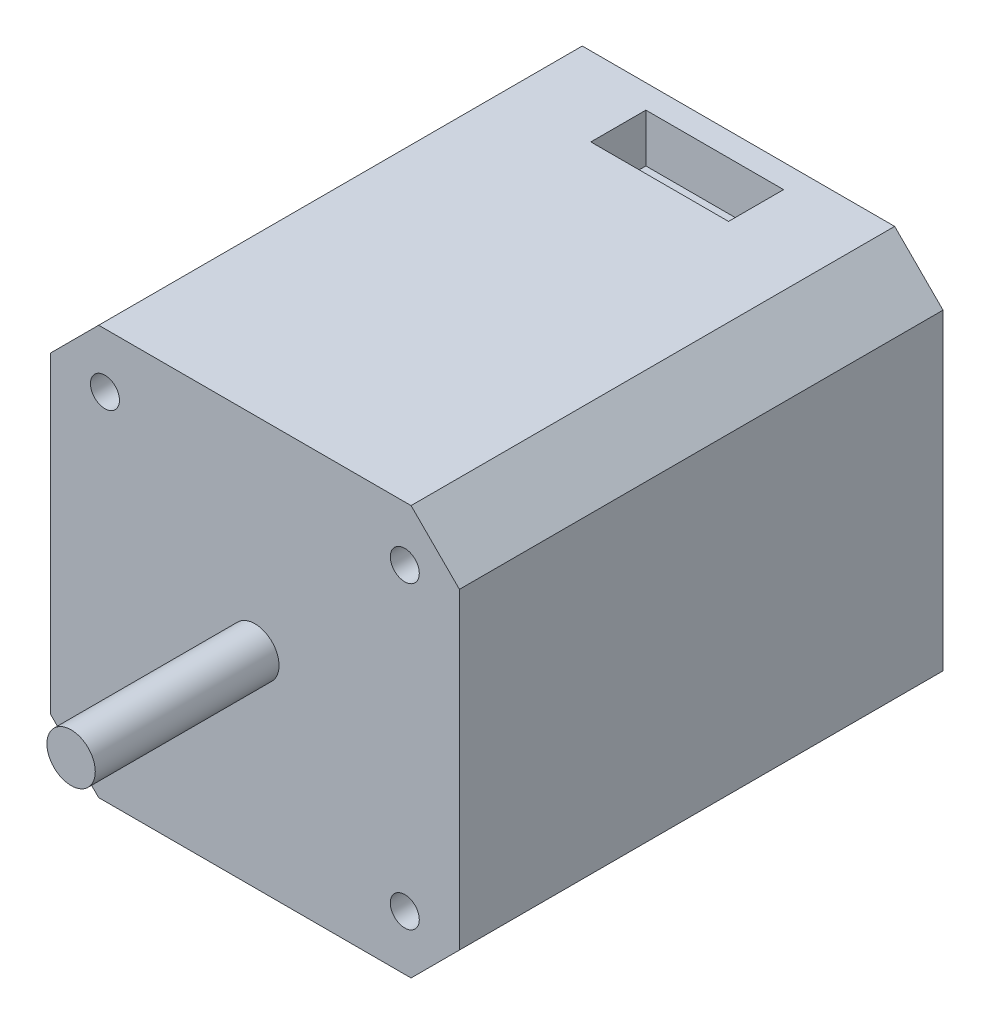
from build123d import *

# Parameters (mm, degrees)
BOSS_EXTRUDE1_DEPTH = 50
SKETCH2_R           = 2.5
BOSS_EXTRUDE2_DEPTH = 24
SKETCH3_R           = 1.5
CUT_EXTRUDE1_DEPTH  = 24
SKETCH4_W           = 14.23576085
SKETCH4_H           = 5.694304341
CUT_EXTRUDE2_DEPTH  = 5
SKETCH6_R           = 2.5
CUT_EXTRUDE3_DEPTH  = 5


with BuildPart() as part:
    # Sketch1 → Boss-Extrude1 (new body)
    with BuildSketch(Plane.XY):
        Polygon((-16.15, 21.15), (-21.15, 16.15), (-21.15, -16.15), (-16.15, -21.15), (16.15, -21.15), (21.15, -16.15), (21.15, 16.15), (16.15, 21.15), align=None)
    extrude(amount=BOSS_EXTRUDE1_DEPTH)

    # Sketch2 → Boss-Extrude2 (add)
    with BuildSketch(Plane.XY.offset(50)):
        Circle(SKETCH2_R)
    extrude(amount=BOSS_EXTRUDE2_DEPTH)

    # Sketch3 → Cut-Extrude1 (cut)
    with BuildSketch(Plane.XY.offset(50)):
        with Locations((-15.5, 15.5)):
            Circle(SKETCH3_R)
        with Locations((-15.5, -15.5)):
            Circle(SKETCH3_R)
        with Locations((15.5, -15.5)):
            Circle(SKETCH3_R)
        with Locations((15.5, 15.5)):
            Circle(SKETCH3_R)
    extrude(amount=-CUT_EXTRUDE1_DEPTH, mode=Mode.SUBTRACT)

    # Sketch4 → Cut-Extrude2 (cut)
    with BuildSketch(Plane(origin=(0, 21.15, 0), x_dir=(1, 0, 0), z_dir=(0, 1, 0))):
        with Locations((0, -5.299206554)):
            Rectangle(SKETCH4_W, SKETCH4_H)
    extrude(amount=-CUT_EXTRUDE2_DEPTH, mode=Mode.SUBTRACT)

    # Sketch6 → Cut-Extrude3 (cut)
    with BuildSketch(Plane.XY.offset(74)):
        Circle(SKETCH6_R)
    extrude(amount=-CUT_EXTRUDE3_DEPTH, mode=Mode.SUBTRACT)


solid = part.part
